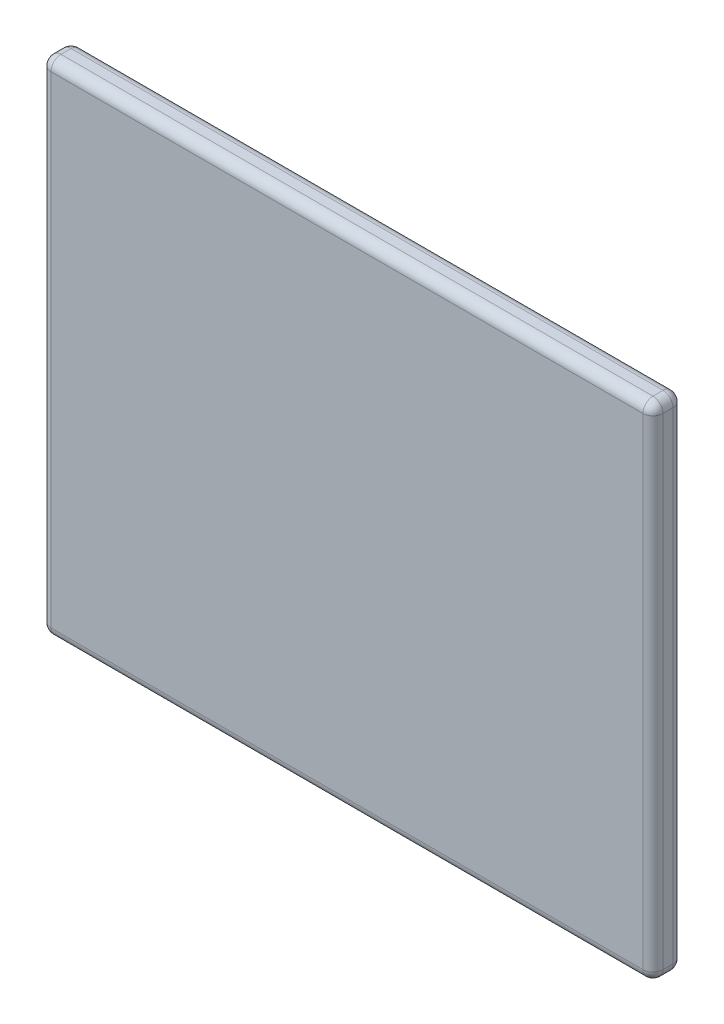
from build123d import *

# Parameters (mm, degrees)
SKETCH_1_W      = 61
SKETCH_1_H      = 50
EXTRUDE_1_DEPTH = 3
FILLET_1_R      = 1


with BuildPart() as part:
    # 草图1 → 凸台-拉伸1 (new body)
    with BuildSketch(Plane.XY):
        Rectangle(SKETCH_1_W, SKETCH_1_H)
    extrude(amount=EXTRUDE_1_DEPTH)

    # 圆角1
    fillet_1_edges = [part.edges().sort_by_distance(p)[0] for p in [
        (-30.5, 0, 3),
        (0, -25, 3),
        (30.5, 0, 3),
        (0, -25, 0),
        (-30.5, 0, 0),
        (0, 25, 0),
        (30.5, 0, 0),
        (30.5, -25, 1.5),
        (-30.5, -25, 1.5),
        (-30.5, 25, 1.5),
        (30.5, 25, 1.5),
        (0, 25, 3),
    ]]
    fillet(fillet_1_edges, radius=FILLET_1_R)


solid = part.part
